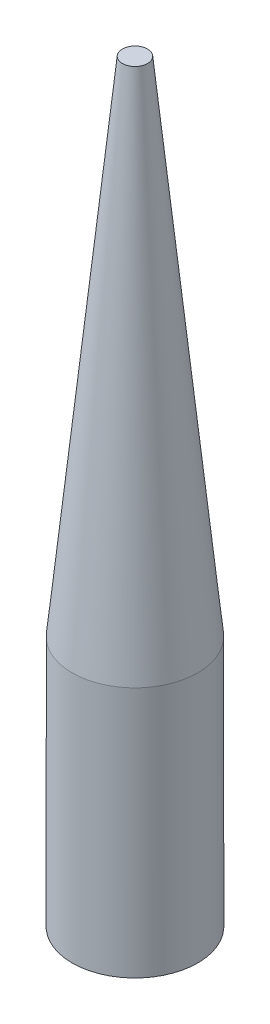
from build123d import *

# Parameters (mm, degrees)
SKETCH1_R           = 2.5
BOSS_EXTRUDE1_DEPTH = 10


with BuildPart() as part:
    # Sketch1 → Boss-Extrude1 (new body)
    with BuildSketch(Plane(origin=(0, 0, 0), x_dir=(1, 0, 0), z_dir=(0, 1, 0))):
        Circle(SKETCH1_R)
    extrude(amount=BOSS_EXTRUDE1_DEPTH)

    # Sketch3 → Revolve1 (revolve)
    with BuildSketch(Plane.XY):
        Polygon((0, 30), (0.5, 30), (2.5, 10), (0, 10), align=None)
    revolve(axis=Axis((0, 10, 0), (0, 1, 0)))


solid = part.part
